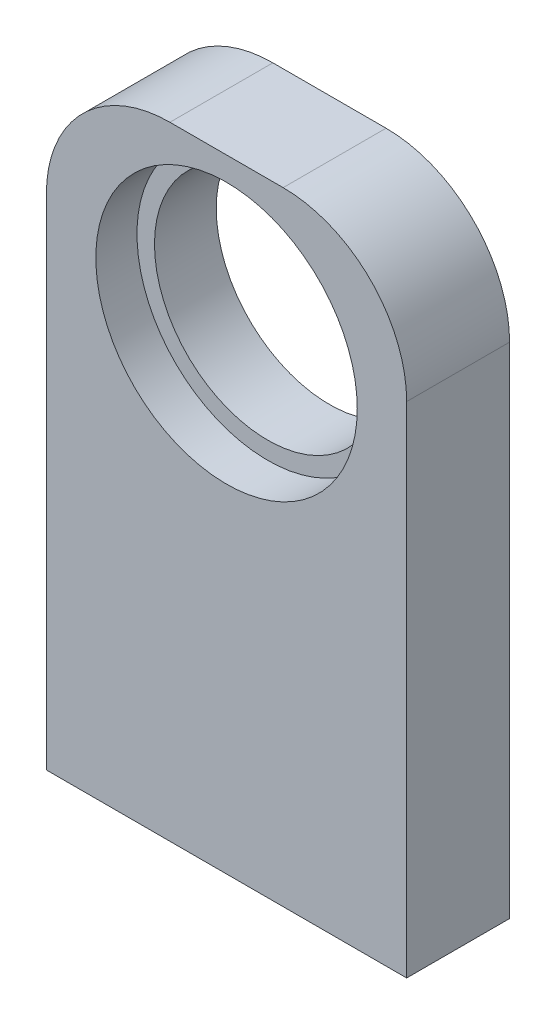
from build123d import *

# Parameters (mm, degrees)
SKETCH1_W           = 35
SKETCH1_H           = 10
BOSS_EXTRUDE1_DEPTH = 60.5
SKETCH2_R           = 11
CUT_EXTRUDE1_DEPTH  = 11
SKETCH3_R           = 1.75
CUT_EXTRUDE2_DEPTH  = 10
FILLET1_R           = 12
SKETCH4_R           = 12.7
CUT_EXTRUDE3_DEPTH  = 4


with BuildPart() as part:
    # Sketch1 → Boss-Extrude1 (new body)
    with BuildSketch(Plane(origin=(0, 0, 0), x_dir=(1, 0, 0), z_dir=(0, 1, 0))):
        with Locations((1.164675851, 0)):
            Rectangle(SKETCH1_W, SKETCH1_H)
    extrude(amount=BOSS_EXTRUDE1_DEPTH)

    # Sketch2 → Cut-Extrude1 (cut, through all)
    with BuildSketch(Plane.XY.offset(5)):
        with Locations((1.164675851, 45.5)):
            Circle(SKETCH2_R)
    extrude(amount=-CUT_EXTRUDE1_DEPTH, mode=Mode.SUBTRACT)

    # Sketch3 → Cut-Extrude2 (cut)
    with BuildSketch(Plane.XZ):
        with Locations((-8.335324149, 0)):
            Circle(SKETCH3_R)
        with Locations((10.664675851, 0)):
            Circle(SKETCH3_R)
    extrude(amount=-CUT_EXTRUDE2_DEPTH, mode=Mode.SUBTRACT)

    # Fillet1
    fillet1_edges = [part.edges().sort_by_distance(p)[0] for p in [
        (18.664675851, 60.5, 0),
        (-16.335324149, 60.5, 0),
    ]]
    fillet(fillet1_edges, radius=FILLET1_R)

    # Sketch4 → Cut-Extrude3 (cut)
    with BuildSketch(Plane.XY.offset(5)):
        with Locations((1.164675851, 45.5)):
            Circle(SKETCH4_R)
    extrude(amount=-CUT_EXTRUDE3_DEPTH, mode=Mode.SUBTRACT)


solid = part.part
